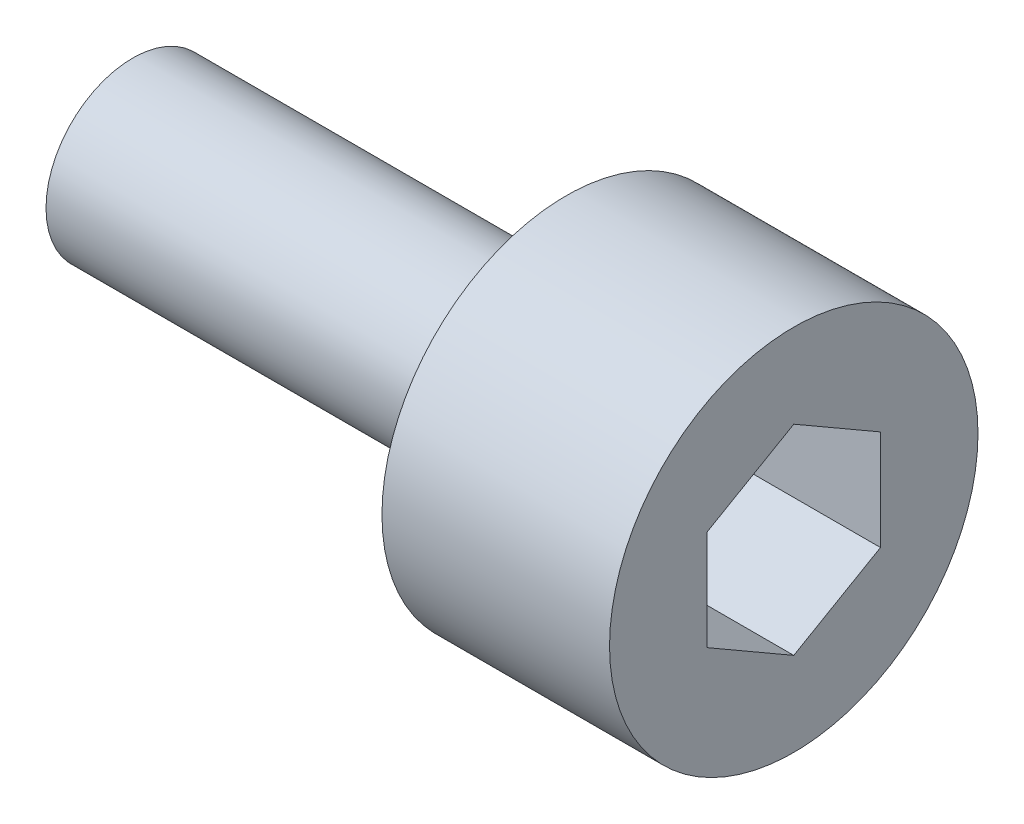
from build123d import *

# Parameters (mm, degrees)
SKETCH1_R           = 4.25
BOSS_EXTRUDE1_DEPTH = 5.25
CUT_EXTRUDE1_DEPTH  = 3.6
SKETCH3_R           = 2
BOSS_EXTRUDE2_DEPTH = 10


with BuildPart() as part:
    # Sketch1 → Boss-Extrude1 (new body)
    with BuildSketch(Plane(origin=(0, 0, 0), x_dir=(0, 0, -1), z_dir=(1, 0, 0))):
        Circle(SKETCH1_R)
    extrude(amount=BOSS_EXTRUDE1_DEPTH)

    # Sketch2 → Cut-Extrude1 (cut)
    with BuildSketch(Plane(origin=(5.25, 0, 0), x_dir=(0, 0, -1), z_dir=(1, 0, 0))):
        Polygon((0, 2.309401077), (-2, 1.154700538), (-2, -1.154700538), (0, -2.309401077), (2, -1.154700538), (2, 1.154700538), align=None)
    extrude(amount=-CUT_EXTRUDE1_DEPTH, mode=Mode.SUBTRACT)

    # Sketch3 → Boss-Extrude2 (add)
    with BuildSketch(Plane.ZY):
        Circle(SKETCH3_R)
    extrude(amount=BOSS_EXTRUDE2_DEPTH)


solid = part.part
